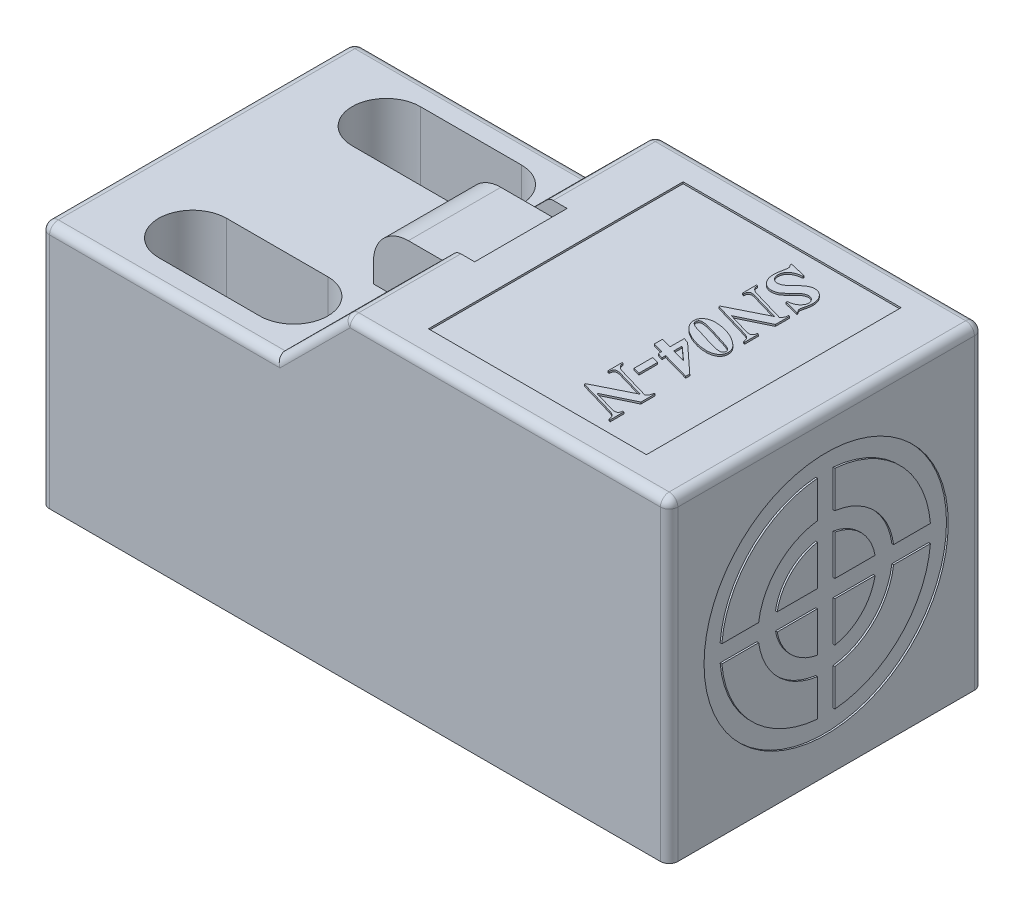
from build123d import *

# Parameters (mm, degrees)
EXTRUDE1_DEPTH  = 18
EXTRUDE2_DEPTH  = 17.9
LPATTERN1_COUNT = 2
LPATTERN1_PITCH = 11.1
SKETCH3_W       = 5.8
SKETCH3_H       = 5.3
EXTRUDE3_DEPTH  = 5
SKETCH4_W       = 5.8
SKETCH4_H       = 5.3
EXTRUDE4_DEPTH  = 1.85
FILLET1_R       = 2
EXTRUDE5_DEPTH  = 1.2
SKETCH6_R       = 1.6
EXTRUDE6_DEPTH  = 1
SKETCH7_W       = 12.5
SKETCH7_H       = 14.6
EXTRUDE7_DEPTH  = 0.1
SKETCH8_R       = 7
EXTRUDE8_DEPTH  = 0.1
FILLET3_R       = 0.5
EXTRUDE10_DEPTH = 0.1


with BuildPart() as part:
    # Sketch1 → Extrude1 (new body)
    with BuildSketch(Plane.XY):
        Polygon((-66.946751975, 32.479243645), (-48.446751975, 32.479243645), (-48.446751975, 14.379243645), (-84.466751975, 14.379243645), (-84.466751975, 28.479243645), (-70.966751975, 28.479243645), align=None)
    extrude(amount=EXTRUDE1_DEPTH)

    # Sketch2 → Extrude2 (cut)
    with BuildSketch(Plane(origin=(0, 28.479243645, 0), x_dir=(1, 0, 0), z_dir=(0, 1, 0))):
        with BuildLine():
            Line((-79.216751975, -12.6), (-73.416751975, -12.6))
            ThreePointArc((-73.416751975, -12.6), (-71.466751975, -14.55), (-73.416751975, -16.5))
            Line((-73.416751975, -16.5), (-79.216751975, -16.5))
            ThreePointArc((-79.216751975, -16.5), (-81.166751975, -14.55), (-79.216751975, -12.6))
        make_face()
    extrude2 = extrude(amount=-EXTRUDE2_DEPTH, mode=Mode.SUBTRACT)

    # LPattern1: Extrude2 ×2
    with Locations(*[(0, 0, -i * LPATTERN1_PITCH) for i in range(1, LPATTERN1_COUNT)]):
        add(extrude2, mode=Mode.SUBTRACT)

    # Sketch3 → Extrude3 (add)
    with BuildSketch(Plane(origin=(0, 28.479243645, 0), x_dir=(1, 0, 0), z_dir=(0, 1, 0))):
        with Locations((-68.846751975, -9)):
            Rectangle(SKETCH3_W, SKETCH3_H)
    extrude(amount=EXTRUDE3_DEPTH)

    # Sketch4 → Extrude4 (cut)
    with BuildSketch(Plane(origin=(0, 33.479243645, 0), x_dir=(1, 0, 0), z_dir=(0, 1, 0))):
        with Locations((-68.846751975, -9)):
            Rectangle(SKETCH4_W, SKETCH4_H)
    extrude(amount=-EXTRUDE4_DEPTH, mode=Mode.SUBTRACT)

    # Fillet1
    fillet1_edges = [part.edges().sort_by_distance(p)[0] for p in [
        (-71.746751975, 31.629243645, 9),
    ]]
    fillet(fillet1_edges, radius=FILLET1_R)

    # Sketch5 → Extrude5 (add)
    with BuildSketch(Plane.ZY.offset(84.466751975)):
        with BuildLine():
            Line((5, 14.379243645), (13, 14.379243645))
            Line((13, 14.379243645), (13, 20.389243645))
            ThreePointArc((13, 20.389243645), (11.831356057, 23.210599701), (9.01, 24.379243645))
            Line((9.01, 24.379243645), (8.99, 24.379243645))
            ThreePointArc((8.99, 24.379243645), (6.168643943, 23.210599701), (5, 20.389243645))
            Line((5, 20.389243645), (5, 14.379243645))
        make_face()
    extrude(amount=EXTRUDE5_DEPTH)

    # Sketch6 → Extrude6 (add)
    with BuildSketch(Plane.ZY.offset(85.666751975)):
        with Locations((8.99, 20.389243645)):
            Circle(SKETCH6_R)
    extrude(amount=EXTRUDE6_DEPTH)

    # Sketch7 → Extrude7 (cut)
    with BuildSketch(Plane(origin=(0, 32.479243645, 0), x_dir=(1, 0, 0), z_dir=(0, 1, 0))):
        with Locations((-57.696751975, -9)):
            Rectangle(SKETCH7_W, SKETCH7_H)
    extrude(amount=-EXTRUDE7_DEPTH, mode=Mode.SUBTRACT)

    # Sketch8 → Extrude8 (cut)
    with BuildSketch(Plane(origin=(-48.446751975, 0, 0), x_dir=(0, 0, -1), z_dir=(1, 0, 0))):
        with Locations((-9, 23.429243645)):
            Circle(SKETCH8_R)
        with BuildLine():
            Line((-9.5, 26.235041214), (-9.5, 23.929243645))
            Line((-9.5, 23.929243645), (-11.805797569, 23.929243645))
            ThreePointArc((-11.805797569, 23.929243645), (-11.015254326, 25.444497971), (-9.5, 26.235041214))
        make_face(mode=Mode.SUBTRACT)
        with BuildLine():
            Line((-14.979130372, 23.929243645), (-12.867815921, 23.929243645))
            ThreePointArc((-12.867815921, 23.929243645), (-11.757716447, 26.186960091), (-9.5, 27.297059566))
            Line((-9.5, 27.297059566), (-9.5, 29.408374016))
            ThreePointArc((-9.5, 29.408374016), (-13.242640687, 27.671884332), (-14.979130372, 23.929243645))
        make_face(mode=Mode.SUBTRACT)
        with BuildLine():
            Line((-8.5, 26.235041214), (-8.5, 23.929243645))
            Line((-8.5, 23.929243645), (-6.194202431, 23.929243645))
            ThreePointArc((-6.194202431, 23.929243645), (-6.984745674, 25.444497971), (-8.5, 26.235041214))
        make_face(mode=Mode.SUBTRACT)
        with BuildLine():
            Line((-8.5, 29.408374016), (-8.5, 27.297059566))
            ThreePointArc((-8.5, 27.297059566), (-6.242283553, 26.186960091), (-5.132184079, 23.929243645))
            Line((-5.132184079, 23.929243645), (-3.020869628, 23.929243645))
            ThreePointArc((-3.020869628, 23.929243645), (-4.757359313, 27.671884332), (-8.5, 29.408374016))
        make_face(mode=Mode.SUBTRACT)
        with BuildLine():
            Line((-5.132184079, 22.929243645), (-3.020869628, 22.929243645))
            ThreePointArc((-3.020869628, 22.929243645), (-4.757359313, 19.186602957), (-8.5, 17.450113273))
            Line((-8.5, 17.450113273), (-8.5, 19.561427723))
            ThreePointArc((-8.5, 19.561427723), (-6.242283553, 20.671527198), (-5.132184079, 22.929243645))
        make_face(mode=Mode.SUBTRACT)
        with BuildLine():
            Line((-14.979130372, 22.929243645), (-12.867815921, 22.929243645))
            ThreePointArc((-12.867815921, 22.929243645), (-11.757716447, 20.671527198), (-9.5, 19.561427723))
            Line((-9.5, 19.561427723), (-9.5, 17.450113273))
            ThreePointArc((-9.5, 17.450113273), (-13.242640687, 19.186602957), (-14.979130372, 22.929243645))
        make_face(mode=Mode.SUBTRACT)
        with BuildLine():
            Line((-9.5, 22.929243645), (-9.5, 20.623446075))
            ThreePointArc((-9.5, 20.623446075), (-11.015254326, 21.413989318), (-11.805797569, 22.929243645))
            Line((-11.805797569, 22.929243645), (-9.5, 22.929243645))
        make_face(mode=Mode.SUBTRACT)
        with BuildLine():
            Line((-8.5, 22.929243645), (-8.5, 20.623446075))
            ThreePointArc((-8.5, 20.623446075), (-6.984745674, 21.413989318), (-6.194202431, 22.929243645))
            Line((-6.194202431, 22.929243645), (-8.5, 22.929243645))
        make_face(mode=Mode.SUBTRACT)
    extrude(amount=-EXTRUDE8_DEPTH, mode=Mode.SUBTRACT)

    # Fillet3
    fillet3_edges = [part.edges().sort_by_distance(p)[0] for p in [
        (-66.946751975, 32.479243645, 3.175),
        (-66.946751975, 32.479243645, 14.825),
        (-57.696751975, 32.479243645, 18),
        (-68.956751975, 30.479243645, 18),
        (-77.716751975, 28.479243645, 18),
        (-84.466751975, 21.429243645, 18),
        (-48.446751975, 23.429243645, 18),
        (-84.466751975, 28.479243645, 9),
        (-84.466751975, 21.429243645, 0),
        (-77.716751975, 28.479243645, 0),
        (-68.956751975, 30.479243645, 0),
        (-48.446751975, 23.429243645, 0),
        (-48.446751975, 32.479243645, 9),
        (-57.696751975, 32.479243645, 0),
    ]]
    fillet(fillet3_edges, radius=FILLET3_R)

    # Sketch12 → Extrude10 (add)
    with BuildSketch(Plane(origin=(0, 32.379243645, 0), x_dir=(-1, 0, 0), z_dir=(0, 1, 0))):
        with BuildLine():
            Line((54.217585308, 13.848090278), (55.926569683, 14.672743056))
            Line((55.926569683, 14.672743056), (54.697728537, 15.036241319))
            add(Edge.make_bspline(
                [(54.697728537, 15.036241319), (54.680770727, 15.040417409), (54.647928955, 15.048505139), (54.599724774, 15.056993208), (54.554470721, 15.063025175), (54.525220345, 15.063622276), (54.511096593, 15.06391059)],
                knots=[0, 0, 0, 0, 5.2376e-05, 0.000101436, 0.000146792, 0.000189141, 0.000189141, 0.000189141, 0.000189141], degree=3))
            add(Edge.make_bspline(
                [(54.511096593, 15.06391059), (54.495660528, 15.063188838), (54.465825954, 15.061793846), (54.423520353, 15.050905397), (54.386009201, 15.032506175), (54.353030605, 15.006683404), (54.326421974, 14.970974423), (54.306166824, 14.925521479), (54.293462491, 14.869711329), (54.289272375, 14.829052805), (54.287029753, 14.807291667)],
                knots=[0, 0, 0, 0, 4.6272e-05, 8.9433e-05, 0.000129953, 0.000170877, 0.000213847, 0.00026216, 0.000319137, 0.000384747, 0.000384747, 0.000384747, 0.000384747], degree=3))
            Line((54.287029753, 14.807291667), (54.217585308, 14.827365451))
            Line((54.217585308, 14.827365451), (54.217585308, 15.614040799))
            Line((54.217585308, 15.614040799), (54.287029753, 15.595594618))
            add(Edge.make_bspline(
                [(54.287029753, 15.595594618), (54.289286674, 15.571630477), (54.293663741, 15.525154502), (54.310486441, 15.459042694), (54.335936725, 15.399579854), (54.363275272, 15.354199491), (54.392013639, 15.32227373), (54.417481963, 15.298496648), (54.448932431, 15.277304402), (54.484255978, 15.256157011), (54.523972054, 15.235110284), (54.569197382, 15.216826207), (54.618575853, 15.197962016), (54.653530655, 15.187220158), (54.671686871, 15.181640625)],
                knots=[0, 0, 0, 0, 7.2139e-05, 0.000139906, 0.000203593, 0.00026576, 0.000297659, 0.00033222, 0.000369999, 0.000411124, 0.000455774, 0.000504644, 0.000557348, 0.000614312, 0.000614312, 0.000614312, 0.000614312], degree=3))
            Line((54.671686871, 15.181640625), (56.717585308, 14.582139757))
            Line((56.717585308, 14.582139757), (56.717585308, 14.520833333))
            Line((56.717585308, 14.520833333), (54.628284093, 13.475911458))
            Line((54.628284093, 13.475911458), (56.278132183, 12.99468316))
            add(Edge.make_bspline(
                [(56.278132183, 12.99468316), (56.305120853, 12.987961491), (56.355417393, 12.975434875), (56.407152473, 12.97264638), (56.431126975, 12.971354167)],
                knots=[0, 0, 0, 0, 8.3211e-05, 0.000155074, 0.000155074, 0.000155074, 0.000155074], degree=3))
            add(Edge.make_bspline(
                [(56.431126975, 12.971354167), (56.446775033, 12.971935765), (56.477170895, 12.9730655), (56.520027609, 12.986041052), (56.558083011, 13.006488341), (56.591007111, 13.035434664), (56.617629686, 13.073943195), (56.63561898, 13.122344572), (56.646271582, 13.179947477), (56.647487184, 13.221410316), (56.648140864, 13.243706597)],
                knots=[0, 0, 0, 0, 4.6812e-05, 9.0931e-05, 0.000132931, 0.000175599, 0.000221201, 0.000271878, 0.000329335, 0.000396175, 0.000396175, 0.000396175, 0.000396175], degree=3))
            Line((56.648140864, 13.243706597), (56.717585308, 13.227430556))
            Line((56.717585308, 13.227430556), (56.717585308, 12.417426215))
            Line((56.717585308, 12.417426215), (56.648140864, 12.433702257))
            add(Edge.make_bspline(
                [(56.648140864, 12.433702257), (56.647971318, 12.449987788), (56.647660068, 12.479884593), (56.644547386, 12.521040216), (56.63933653, 12.554709903), (56.632637568, 12.573918393), (56.629694683, 12.582356771)],
                knots=[0, 0, 0, 0, 4.884e-05, 8.966e-05, 0.000123823, 0.000150589, 0.000150589, 0.000150589, 0.000150589], degree=3))
            add(Edge.make_bspline(
                [(56.629694683, 12.582356771), (56.624140867, 12.595416153), (56.612704566, 12.622307756), (56.586595207, 12.659979875), (56.554461873, 12.697252537), (56.515886075, 12.734622762), (56.468783261, 12.769419962), (56.412526981, 12.801089882), (56.34696509, 12.82904401), (56.29926507, 12.843761717), (56.27433444, 12.851453993)],
                knots=[0, 0, 0, 0, 4.2477e-05, 8.7469e-05, 0.000136723, 0.00019006, 0.00024822, 0.000311879, 0.000383331, 0.000461566, 0.000461566, 0.000461566, 0.000461566], degree=3))
            Line((56.27433444, 12.851453993), (54.45901326, 13.382052951))
            add(Edge.make_bspline(
                [(54.45901326, 13.382052951), (54.442312569, 13.367118213), (54.411205191, 13.339300168), (54.37160966, 13.297050314), (54.341169804, 13.258973076), (54.318437097, 13.222982605), (54.304452683, 13.183716381), (54.295198532, 13.13881583), (54.288629426, 13.086010291), (54.28758678, 13.048055097), (54.287029753, 13.027777778)],
                knots=[0, 0, 0, 0, 6.7189e-05, 0.000125149, 0.000173447, 0.000213363, 0.00025216, 0.000297707, 0.000350735, 0.000411559, 0.000411559, 0.000411559, 0.000411559], degree=3))
            Line((54.287029753, 13.027777778), (54.217585308, 13.027777778))
            Line((54.217585308, 13.027777778), (54.217585308, 13.848090278))
        make_face()
        Polygon((55.710640864, 11.395833333), (55.710640864, 12.472222222), (56.092585308, 12.368055556), (56.092585308, 11.291666667), align=None)
        Polygon((56.12730753, 10.274956597), (56.12730753, 9.451388889), (55.834881315, 9.555555556), (54.217585308, 11.048611111), (54.217585308, 11.281901042), (55.81480753, 10.831054687), (55.81480753, 11.048611111), (56.12730753, 10.944444444), (56.12730753, 10.743164062), (56.717585308, 10.576605903), (56.717585308, 10.108398437), align=None)
        Polygon((55.81480753, 10.362847222), (55.036812739, 10.582573785), (55.81480753, 9.886501736), align=None, mode=Mode.SUBTRACT)
        with BuildLine():
            add(Edge.make_bspline(
                [(54.182863086, 8.87358941), (54.184073107, 8.902277151), (54.186429627, 8.95814661), (54.206051358, 9.038769036), (54.238065837, 9.113086374), (54.28410285, 9.179601659), (54.339840378, 9.238578555), (54.404850306, 9.289131258), (54.478375762, 9.33064365), (54.559399701, 9.362355092), (54.643984551, 9.385996948), (54.729207587, 9.403420534), (54.813692255, 9.415005581), (54.870037246, 9.41611673), (54.89792385, 9.416666667)],
                knots=[0, 0, 0, 0, 8.5967e-05, 0.000167422, 0.000247353, 0.000327408, 0.00040877, 0.000489947, 0.000573526, 0.000661175, 0.000750304, 0.000836702, 0.00092203, 0.001005644, 0.001005644, 0.001005644, 0.001005644], degree=3))
            add(Edge.make_bspline(
                [(54.89792385, 9.416666667), (54.946602995, 9.415663052), (55.04488093, 9.413636864), (55.193295036, 9.398996546), (55.343857591, 9.375143042), (55.495133524, 9.341338623), (55.64475773, 9.300364767), (55.789328928, 9.250609989), (55.928307477, 9.194577375), (56.05964948, 9.129825518), (56.183530154, 9.061208726), (56.297225446, 8.987658834), (56.401138961, 8.911074603), (56.463552935, 8.854921635), (56.494061003, 8.827473958)],
                knots=[0, 0, 0, 0, 0.000146024, 0.000294806, 0.000446972, 0.000603091, 0.000759594, 0.00091212, 0.00106153, 0.001208813, 0.001351144, 0.001486132, 0.001614821, 0.001737872, 0.001737872, 0.001737872, 0.001737872], degree=3))
            add(Edge.make_bspline(
                [(56.494061003, 8.827473958), (56.511999376, 8.809380068), (56.548089878, 8.772976679), (56.595539799, 8.711258763), (56.639963861, 8.645136554), (56.678329319, 8.573606989), (56.711062611, 8.499302649), (56.735488665, 8.423098316), (56.749137295, 8.345470029), (56.751252996, 8.293487786), (56.75230753, 8.267578125)],
                knots=[0, 0, 0, 0, 7.6366e-05, 0.000153643, 0.000233092, 0.000315144, 0.000396784, 0.000476402, 0.000554627, 0.000632363, 0.000632363, 0.000632363, 0.000632363], degree=3))
            add(Edge.make_bspline(
                [(56.75230753, 8.267578125), (56.751262696, 8.243982671), (56.749187726, 8.197123741), (56.732562279, 8.128517228), (56.70395784, 8.063796757), (56.666293972, 8.002057848), (56.616694827, 7.946110483), (56.557508962, 7.895635422), (56.487839387, 7.85230173), (56.40945265, 7.816096574), (56.325179526, 7.786477098), (56.236660825, 7.765265233), (56.14521883, 7.752580866), (56.08322121, 7.750866321), (56.051895204, 7.75)],
                knots=[0, 0, 0, 0, 7.0738e-05, 0.00014048, 0.000210223, 0.000282339, 0.000356548, 0.000433519, 0.000514952, 0.00060184, 0.000692094, 0.000782495, 0.000874491, 0.00096845, 0.00096845, 0.00096845, 0.00096845], degree=3))
            add(Edge.make_bspline(
                [(56.051895204, 7.75), (56.01697697, 7.750324468), (55.94705627, 7.750974185), (55.842272889, 7.759160261), (55.737323416, 7.771117017), (55.632182659, 7.786957846), (55.52719588, 7.809254594), (55.422096078, 7.834961154), (55.316927598, 7.865988639), (55.247581201, 7.890224554), (55.212593989, 7.902452257)],
                knots=[0, 0, 0, 0, 0.000104732, 0.000209716, 0.000315103, 0.000421606, 0.00052854, 0.000636966, 0.000746146, 0.000857322, 0.000857322, 0.000857322, 0.000857322], degree=3))
            add(Edge.make_bspline(
                [(55.212593989, 7.902452257), (55.156024735, 7.924098005), (55.045344794, 7.966448752), (54.888262531, 8.041804861), (54.742815702, 8.124126402), (54.631180661, 8.199659151), (54.549555227, 8.262433129), (54.494094262, 8.308135266), (54.443538948, 8.352384521), (54.398406653, 8.395961654), (54.358155105, 8.438102306), (54.32302898, 8.479352121), (54.293903119, 8.520095509), (54.261465337, 8.571628412), (54.229962243, 8.636286645), (54.203318172, 8.715107287), (54.186035986, 8.79417427), (54.183914147, 8.847282195), (54.182863086, 8.87358941)],
                knots=[0, 0, 0, 0, 0.000181645, 0.000355396, 0.000522082, 0.00068264, 0.000759251, 0.000830939, 0.000898207, 0.000960749, 0.001019081, 0.001072986, 0.001123126, 0.00116919, 0.001255569, 0.001338094, 0.001418427, 0.001497282, 0.001497282, 0.001497282, 0.001497282], degree=3))
        make_face()
        with BuildLine():
            add(Edge.make_bspline(
                [(54.287029753, 8.895833333), (54.288042002, 8.877841001), (54.289967896, 8.843609005), (54.303127144, 8.802199263), (54.322120838, 8.773549375), (54.340805233, 8.75094087), (54.36542117, 8.728156338), (54.389454289, 8.708090337), (54.413300391, 8.691928999), (54.436475986, 8.678991558), (54.463938061, 8.66495514), (54.496271088, 8.650382963), (54.532932808, 8.634684887), (54.57420812, 8.618473607), (54.620037451, 8.601658577), (54.652142072, 8.590348278), (54.668974197, 8.584418403)],
                knots=[0, 0, 0, 0, 5.3984e-05, 0.00010271, 0.000127843, 0.00015674, 0.000190508, 0.000228299, 0.000250569, 0.000276814, 0.000307871, 0.000343073, 0.000383181, 0.000427509, 0.000476087, 0.000529625, 0.000529625, 0.000529625, 0.000529625], degree=3))
            add(Edge.make_bspline(
                [(54.668974197, 8.584418403), (54.701869723, 8.572971863), (54.769387367, 8.549477987), (54.873447318, 8.51442673), (54.982532774, 8.477811304), (55.097133902, 8.441114344), (55.21703316, 8.403133402), (55.342264402, 8.363936981), (55.472967565, 8.32458109), (55.561802775, 8.297950648), (55.607016732, 8.284396701)],
                knots=[0, 0, 0, 0, 0.00010449, 0.000214464, 0.000329412, 0.000449685, 0.000575456, 0.000706728, 0.000843345, 0.000984951, 0.000984951, 0.000984951, 0.000984951], degree=3))
            add(Edge.make_bspline(
                [(55.607016732, 8.284396701), (55.641000335, 8.274397342), (55.705678277, 8.25536646), (55.798045526, 8.229076342), (55.880432113, 8.204645895), (55.953727651, 8.185047214), (56.01706595, 8.167347966), (56.071062768, 8.15346937), (56.115174105, 8.141600201), (56.14175304, 8.136010699), (56.153349197, 8.133572049)],
                knots=[0, 0, 0, 0, 0.000106272, 0.000202257, 0.000288108, 0.000364052, 0.000429859, 0.000485392, 0.000531315, 0.000566859, 0.000566859, 0.000566859, 0.000566859], degree=3))
            add(Edge.make_bspline(
                [(56.153349197, 8.133572049), (56.181157321, 8.128083401), (56.234613431, 8.117532466), (56.312633483, 8.106182338), (56.385218072, 8.098489059), (56.432013688, 8.097632846), (56.454455968, 8.097222222)],
                knots=[0, 0, 0, 0, 8.5019e-05, 0.000163433, 0.000236474, 0.000303784, 0.000303784, 0.000303784, 0.000303784], degree=3))
            add(Edge.make_bspline(
                [(56.454455968, 8.097222222), (56.468799826, 8.097810642), (56.496009448, 8.098926845), (56.534553818, 8.108315683), (56.568403318, 8.12407601), (56.596769411, 8.146724824), (56.619529038, 8.173758032), (56.636175391, 8.2041694), (56.646448929, 8.237630983), (56.647566396, 8.260993341), (56.648140864, 8.273003472)],
                knots=[0, 0, 0, 0, 4.2984e-05, 8.1538e-05, 0.000118182, 0.000154108, 0.000189536, 0.000223525, 0.000257511, 0.000293466, 0.000293466, 0.000293466, 0.000293466], degree=3))
            add(Edge.make_bspline(
                [(56.648140864, 8.273003472), (56.647643881, 8.285533338), (56.646690289, 8.309575205), (56.638752435, 8.343752456), (56.626752723, 8.374954205), (56.61383207, 8.392417042), (56.60745076, 8.401041667)],
                knots=[0, 0, 0, 0, 3.7533e-05, 7.2017e-05, 0.000104862, 0.000136913, 0.000136913, 0.000136913, 0.000136913], degree=3))
            add(Edge.make_bspline(
                [(56.60745076, 8.401041667), (56.59175107, 8.417977243), (56.558599868, 8.453738123), (56.493394786, 8.496726648), (56.416080054, 8.537522352), (56.357858201, 8.558235252), (56.326960308, 8.569227431)],
                knots=[0, 0, 0, 0, 6.9053e-05, 0.000145812, 0.000232685, 0.000330922, 0.000330922, 0.000330922, 0.000330922], degree=3))
            add(Edge.make_bspline(
                [(56.326960308, 8.569227431), (56.286442754, 8.582583874), (56.201985777, 8.610424764), (56.070167023, 8.654465237), (55.926700936, 8.698738049), (55.772897813, 8.747549639), (55.607686949, 8.797460951), (55.432248398, 8.851763847), (55.245281936, 8.906534566), (55.117274553, 8.944614429), (55.051461176, 8.964192708)],
                knots=[0, 0, 0, 0, 0.000127988, 0.000266784, 0.000416925, 0.000578394, 0.00075087, 0.000934674, 0.001129337, 0.001335329, 0.001335329, 0.001335329, 0.001335329], degree=3))
            add(Edge.make_bspline(
                [(55.051461176, 8.964192708), (55.022358885, 8.972375609), (54.966062715, 8.988204808), (54.883993542, 9.010485274), (54.80637077, 9.027917765), (54.733652176, 9.043696954), (54.66552357, 9.054855787), (54.602214027, 9.063196124), (54.54373568, 9.068373989), (54.506222926, 9.069098488), (54.488310135, 9.069444444)],
                knots=[0, 0, 0, 0, 9.0696e-05, 0.000175444, 0.000255066, 0.000329335, 0.000398638, 0.000462096, 0.000520893, 0.000574628, 0.000574628, 0.000574628, 0.000574628], degree=3))
            add(Edge.make_bspline(
                [(54.488310135, 9.069444444), (54.473436268, 9.068819417), (54.445002973, 9.067624599), (54.404491462, 9.058580937), (54.369227667, 9.042112915), (54.339773568, 9.019620384), (54.316126257, 8.993118948), (54.299721436, 8.96293923), (54.288600318, 8.930418908), (54.287559585, 8.907500819), (54.287029753, 8.895833333)],
                knots=[0, 0, 0, 0, 4.4607e-05, 8.5272e-05, 0.000123619, 0.000160404, 0.000195773, 0.000229287, 0.000262915, 0.00029779, 0.00029779, 0.00029779, 0.00029779], degree=3))
        make_face(mode=Mode.SUBTRACT)
        with BuildLine():
            Line((54.217585308, 6.139756944), (55.926569683, 6.964409722))
            Line((55.926569683, 6.964409722), (54.697728537, 7.327907986))
            add(Edge.make_bspline(
                [(54.697728537, 7.327907986), (54.680770727, 7.332084076), (54.647928955, 7.340171806), (54.599724774, 7.348659874), (54.554470721, 7.354691842), (54.525220345, 7.355288943), (54.511096593, 7.355577257)],
                knots=[0, 0, 0, 0, 5.2376e-05, 0.000101436, 0.000146792, 0.000189141, 0.000189141, 0.000189141, 0.000189141], degree=3))
            add(Edge.make_bspline(
                [(54.511096593, 7.355577257), (54.495660528, 7.354855504), (54.465825954, 7.353460512), (54.423520353, 7.342572063), (54.386009201, 7.324172842), (54.353030605, 7.29835007), (54.326421974, 7.262641089), (54.306166824, 7.217188145), (54.293462491, 7.161377995), (54.289272375, 7.120719471), (54.287029753, 7.098958333)],
                knots=[0, 0, 0, 0, 4.6272e-05, 8.9433e-05, 0.000129953, 0.000170877, 0.000213847, 0.00026216, 0.000319137, 0.000384747, 0.000384747, 0.000384747, 0.000384747], degree=3))
            Line((54.287029753, 7.098958333), (54.217585308, 7.119032118))
            Line((54.217585308, 7.119032118), (54.217585308, 7.905707465))
            Line((54.217585308, 7.905707465), (54.287029753, 7.887261285))
            add(Edge.make_bspline(
                [(54.287029753, 7.887261285), (54.289286674, 7.863297144), (54.293663741, 7.816821169), (54.310486441, 7.750709361), (54.335936725, 7.691246521), (54.363275272, 7.645866158), (54.392013639, 7.613940397), (54.417481963, 7.590163315), (54.448932431, 7.568971069), (54.484255978, 7.547823678), (54.523972054, 7.52677695), (54.569197382, 7.508492874), (54.618575853, 7.489628682), (54.653530655, 7.478886825), (54.671686871, 7.473307292)],
                knots=[0, 0, 0, 0, 7.2139e-05, 0.000139906, 0.000203593, 0.00026576, 0.000297659, 0.00033222, 0.000369999, 0.000411124, 0.000455774, 0.000504644, 0.000557348, 0.000614312, 0.000614312, 0.000614312, 0.000614312], degree=3))
            Line((54.671686871, 7.473307292), (56.717585308, 6.873806424))
            Line((56.717585308, 6.873806424), (56.717585308, 6.8125))
            Line((56.717585308, 6.8125), (54.628284093, 5.767578125))
            Line((54.628284093, 5.767578125), (56.278132183, 5.286349826))
            add(Edge.make_bspline(
                [(56.278132183, 5.286349826), (56.305120853, 5.279628157), (56.355417393, 5.267101542), (56.407152473, 5.264313047), (56.431126975, 5.263020833)],
                knots=[0, 0, 0, 0, 8.3211e-05, 0.000155074, 0.000155074, 0.000155074, 0.000155074], degree=3))
            add(Edge.make_bspline(
                [(56.431126975, 5.263020833), (56.446775033, 5.263602431), (56.477170895, 5.264732167), (56.520027609, 5.277707719), (56.558083011, 5.298155008), (56.591007111, 5.32710133), (56.617629686, 5.365609862), (56.63561898, 5.414011239), (56.646271582, 5.471614143), (56.647487184, 5.513076983), (56.648140864, 5.535373264)],
                knots=[0, 0, 0, 0, 4.6812e-05, 9.0931e-05, 0.000132931, 0.000175599, 0.000221201, 0.000271878, 0.000329335, 0.000396175, 0.000396175, 0.000396175, 0.000396175], degree=3))
            Line((56.648140864, 5.535373264), (56.717585308, 5.519097222))
            Line((56.717585308, 5.519097222), (56.717585308, 4.709092882))
            Line((56.717585308, 4.709092882), (56.648140864, 4.725368924))
            add(Edge.make_bspline(
                [(56.648140864, 4.725368924), (56.647971318, 4.741654455), (56.647660068, 4.77155126), (56.644547386, 4.812706882), (56.63933653, 4.84637657), (56.632637568, 4.86558506), (56.629694683, 4.874023438)],
                knots=[0, 0, 0, 0, 4.884e-05, 8.966e-05, 0.000123823, 0.000150589, 0.000150589, 0.000150589, 0.000150589], degree=3))
            add(Edge.make_bspline(
                [(56.629694683, 4.874023438), (56.624140867, 4.88708282), (56.612704566, 4.913974422), (56.586595207, 4.951646542), (56.554461873, 4.988919204), (56.515886075, 5.026289429), (56.468783261, 5.061086629), (56.412526981, 5.092756548), (56.34696509, 5.120710677), (56.29926507, 5.135428384), (56.27433444, 5.14312066)],
                knots=[0, 0, 0, 0, 4.2477e-05, 8.7469e-05, 0.000136723, 0.00019006, 0.00024822, 0.000311879, 0.000383331, 0.000461566, 0.000461566, 0.000461566, 0.000461566], degree=3))
            Line((56.27433444, 5.14312066), (54.45901326, 5.673719618))
            add(Edge.make_bspline(
                [(54.45901326, 5.673719618), (54.442312569, 5.65878488), (54.411205191, 5.630966835), (54.37160966, 5.588716981), (54.341169804, 5.550639743), (54.318437097, 5.514649272), (54.304452683, 5.475383047), (54.295198532, 5.430482496), (54.288629426, 5.377676958), (54.28758678, 5.339721764), (54.287029753, 5.319444444)],
                knots=[0, 0, 0, 0, 6.7189e-05, 0.000125149, 0.000173447, 0.000213363, 0.00025216, 0.000297707, 0.000350735, 0.000411559, 0.000411559, 0.000411559, 0.000411559], degree=3))
            Line((54.287029753, 5.319444444), (54.217585308, 5.319444444))
            Line((54.217585308, 5.319444444), (54.217585308, 6.139756944))
        make_face()
        with BuildLine():
            Line((54.182863086, 4.939670139), (55.016196419, 4.724826389))
            Line((55.016196419, 4.724826389), (55.016196419, 4.661892361))
            add(Edge.make_bspline(
                [(55.016196419, 4.661892361), (54.983952693, 4.658295211), (54.922652927, 4.651456533), (54.835971958, 4.635790102), (54.759287907, 4.616300898), (54.712618057, 4.598969097), (54.690675586, 4.590820313)],
                knots=[0, 0, 0, 0, 9.7306e-05, 0.000184992, 0.000264079, 0.00033426, 0.00033426, 0.00033426, 0.00033426], degree=3))
            add(Edge.make_bspline(
                [(54.690675586, 4.590820313), (54.662463088, 4.577761813), (54.607776743, 4.552449571), (54.533894112, 4.504206166), (54.470347887, 4.449537116), (54.416862481, 4.389511697), (54.374913272, 4.324575371), (54.343819264, 4.256793235), (54.325158393, 4.185632811), (54.32289111, 4.137187333), (54.321751975, 4.112847222)],
                knots=[0, 0, 0, 0, 9.3171e-05, 0.0001806, 0.000263691, 0.000344024, 0.000420923, 0.000494739, 0.00056698, 0.000639924, 0.000639924, 0.000639924, 0.000639924], degree=3))
            add(Edge.make_bspline(
                [(54.321751975, 4.112847222), (54.323106658, 4.089722162), (54.32578691, 4.043969028), (54.347461952, 3.977798959), (54.383136342, 3.91663946), (54.431004215, 3.861934511), (54.486868292, 3.815523071), (54.548780312, 3.781822819), (54.61442174, 3.760476501), (54.65977457, 3.75812479), (54.682537565, 3.756944444)],
                knots=[0, 0, 0, 0, 6.9262e-05, 0.000137035, 0.00020655, 0.000280402, 0.000354037, 0.000423229, 0.000490839, 0.000558968, 0.000558968, 0.000558968, 0.000558968], degree=3))
            add(Edge.make_bspline(
                [(54.682537565, 3.756944444), (54.705379119, 3.758003685), (54.751448317, 3.760140069), (54.820230529, 3.773886146), (54.887835231, 3.797990062), (54.94428922, 3.824504258), (54.990837534, 3.853315695), (55.030176832, 3.881834101), (55.074226573, 3.915907576), (55.121914943, 3.956953591), (55.173816969, 4.004197324), (55.230352862, 4.057448626), (55.291088087, 4.117004633), (55.332234943, 4.159584919), (55.353653017, 4.181749132)],
                knots=[0, 0, 0, 0, 6.8534e-05, 0.000138225, 0.00020943, 0.000283442, 0.000324849, 0.000373475, 0.000429147, 0.000491878, 0.000562167, 0.000639694, 0.000724863, 0.000817325, 0.000817325, 0.000817325, 0.000817325], degree=3))
            add(Edge.make_bspline(
                [(55.353653017, 4.181749132), (55.37056517, 4.199555599), (55.403417336, 4.234144984), (55.452601061, 4.283041264), (55.500513517, 4.326832316), (55.545882997, 4.366761217), (55.589992774, 4.40157067), (55.632253682, 4.431853227), (55.672296765, 4.458328999), (55.72360017, 4.486302463), (55.788331486, 4.514320937), (55.868809977, 4.538190938), (55.952631263, 4.552710496), (56.009520072, 4.554599072), (56.038331836, 4.555555556)],
                knots=[0, 0, 0, 0, 7.3673e-05, 0.000143111, 0.000208, 0.000268378, 0.000324385, 0.00037648, 0.000424334, 0.000468282, 0.000551631, 0.0006354, 0.000719598, 0.000805999, 0.000805999, 0.000805999, 0.000805999], degree=3))
            add(Edge.make_bspline(
                [(56.038331836, 4.555555556), (56.070616622, 4.55431075), (56.134701757, 4.551839818), (56.228784443, 4.531805479), (56.318689872, 4.498163222), (56.403959548, 4.452045087), (56.482938381, 4.393452038), (56.553085271, 4.322128022), (56.613094612, 4.238454222), (56.663164488, 4.143967744), (56.703072978, 4.040481976), (56.731904382, 3.929676597), (56.748805852, 3.812079475), (56.751121175, 3.731500679), (56.75230753, 3.690212674)],
                knots=[0, 0, 0, 0, 9.679e-05, 0.000192128, 0.00028706, 0.00038392, 0.000482011, 0.00058099, 0.000682785, 0.000789823, 0.000900953, 0.001014779, 0.001132631, 0.001256472, 0.001256472, 0.001256472, 0.001256472], degree=3))
            add(Edge.make_bspline(
                [(56.75230753, 3.690212674), (56.751600516, 3.662519848), (56.750094962, 3.60354925), (56.739524226, 3.510299025), (56.723253565, 3.406935056), (56.704208669, 3.316326564), (56.688649796, 3.242442982), (56.677488372, 3.190850146), (56.669202211, 3.143867125), (56.661046965, 3.102241793), (56.65607519, 3.065217429), (56.651237425, 3.033483545), (56.649182115, 3.006461291), (56.648466492, 2.99016338), (56.648140864, 2.982747396)],
                knots=[0, 0, 0, 0, 8.3072e-05, 0.000176897, 0.000281256, 0.000396912, 0.000454585, 0.000507786, 0.000555245, 0.000597705, 0.000634994, 0.000667297, 0.000693969, 0.00071624, 0.00071624, 0.00071624, 0.00071624], degree=3))
            add(Edge.make_bspline(
                [(56.648140864, 2.982747396), (56.649156504, 2.963121309), (56.65111121, 2.925348823), (56.664666747, 2.879110423), (56.683347096, 2.844564562), (56.701429091, 2.815417322), (56.72483558, 2.783663262), (56.742786306, 2.762021511), (56.75230753, 2.750542535)],
                knots=[0, 0, 0, 0, 5.8844e-05, 0.000113252, 0.000142614, 0.000176487, 0.000216096, 0.000260834, 0.000260834, 0.000260834, 0.000260834], degree=3))
            Line((56.75230753, 2.750542535), (56.75230753, 2.68109809))
            Line((56.75230753, 2.68109809), (55.81480753, 2.892686632))
            Line((55.81480753, 2.892686632), (55.81480753, 2.958875868))
            add(Edge.make_bspline(
                [(55.81480753, 2.958875868), (55.855048277, 2.963310921), (55.932886304, 2.971889682), (56.04411551, 2.994535584), (56.146476343, 3.022381578), (56.23964289, 3.057330214), (56.323552549, 3.100174276), (56.397812056, 3.151637591), (56.462242689, 3.211500266), (56.516311511, 3.279451927), (56.560167298, 3.353729916), (56.591022749, 3.434233379), (56.610348982, 3.519667158), (56.612381454, 3.578345743), (56.613418642, 3.608289931)],
                knots=[0, 0, 0, 0, 0.000121397, 0.000234819, 0.000340123, 0.000439372, 0.000532792, 0.000622041, 0.000709562, 0.000795647, 0.000881719, 0.000967257, 0.00105335, 0.001143067, 0.001143067, 0.001143067, 0.001143067], degree=3))
            add(Edge.make_bspline(
                [(56.613418642, 3.608289931), (56.61321502, 3.623143709), (56.612813466, 3.652436232), (56.606387793, 3.695228235), (56.597335184, 3.736327169), (56.584387519, 3.775495856), (56.567184865, 3.812502088), (56.547402432, 3.84823101), (56.522468182, 3.881147311), (56.495123538, 3.912569704), (56.46500831, 3.940925229), (56.43348438, 3.966065409), (56.400685073, 3.987470841), (56.366571479, 4.004995814), (56.330724693, 4.017885793), (56.293975699, 4.02796381), (56.255673836, 4.033197746), (56.229859487, 4.034210753), (56.21682576, 4.034722222)],
                knots=[0, 0, 0, 0, 4.4518e-05, 8.7791e-05, 0.000129514, 0.000170689, 0.000211234, 0.000251812, 0.000292938, 0.000334839, 0.000376671, 0.000416833, 0.000455658, 0.000493994, 0.000531585, 0.000569748, 0.000608111, 0.000647234, 0.000647234, 0.000647234, 0.000647234], degree=3))
            add(Edge.make_bspline(
                [(56.21682576, 4.034722222), (56.194340923, 4.033887932), (56.149534213, 4.032225399), (56.083031194, 4.018712466), (56.018361389, 3.996106324), (55.965094353, 3.970503428), (55.921198695, 3.94395702), (55.884733915, 3.917559464), (55.843699009, 3.886676835), (55.799317178, 3.849575655), (55.751412463, 3.806823068), (55.699501144, 3.758708035), (55.643829201, 3.705130899), (55.58562457, 3.647226128), (55.527087979, 3.588361039), (55.468398601, 3.533609641), (55.411538255, 3.483499557), (55.356009339, 3.438695041), (55.303210479, 3.397537174), (55.251252023, 3.36238784), (55.201718446, 3.33116287), (55.168395677, 3.313504119), (55.152372635, 3.305013021)],
                knots=[0, 0, 0, 0, 6.7414e-05, 0.00013434, 0.000202626, 0.00027251, 0.000311216, 0.000356374, 0.000407482, 0.000465277, 0.00052984, 0.000600096, 0.000677605, 0.00076162, 0.000846403, 0.000926627, 0.001002367, 0.001073711, 0.001140663, 0.001203114, 0.00126183, 0.001316214, 0.001316214, 0.001316214, 0.001316214], degree=3))
            add(Edge.make_bspline(
                [(55.152372635, 3.305013021), (55.128924017, 3.294246112), (55.082505327, 3.272932029), (55.00842894, 3.252189532), (54.932613676, 3.238542869), (54.880984899, 3.236923932), (54.855063607, 3.236111111)],
                knots=[0, 0, 0, 0, 7.7294e-05, 0.00015301, 0.000230073, 0.000307776, 0.000307776, 0.000307776, 0.000307776], degree=3))
            add(Edge.make_bspline(
                [(54.855063607, 3.236111111), (54.83259564, 3.236667006), (54.788318083, 3.237762508), (54.723013354, 3.248594666), (54.659958924, 3.265724117), (54.599367447, 3.290587393), (54.541117979, 3.321534157), (54.485073301, 3.359507074), (54.431679012, 3.404626139), (54.380690427, 3.455922426), (54.334517149, 3.513104738), (54.293384798, 3.574621357), (54.259079362, 3.640684818), (54.231436005, 3.711142859), (54.209836674, 3.785630632), (54.193987491, 3.864172775), (54.184782619, 3.94697353), (54.183512619, 4.003593957), (54.182863086, 4.032552083)],
                knots=[0, 0, 0, 0, 6.7353e-05, 0.000132732, 0.000198017, 0.000262999, 0.000328773, 0.000395585, 0.000465675, 0.000538182, 0.000612237, 0.000685818, 0.00075983, 0.000835088, 0.000912518, 0.000992212, 0.001075191, 0.001162058, 0.001162058, 0.001162058, 0.001162058], degree=3))
            add(Edge.make_bspline(
                [(54.182863086, 4.032552083), (54.183901227, 4.061697447), (54.186132793, 4.124347707), (54.198824357, 4.224396206), (54.219685727, 4.33677795), (54.238541829, 4.415303197), (54.248509787, 4.456814236)],
                knots=[0, 0, 0, 0, 8.7456e-05, 0.000187993, 0.000302175, 0.000430228, 0.000430228, 0.000430228, 0.000430228], degree=3))
            add(Edge.make_bspline(
                [(54.248509787, 4.456814236), (54.254317422, 4.480644772), (54.264929873, 4.524190969), (54.276683824, 4.584306724), (54.285433338, 4.632707357), (54.286551374, 4.661505949), (54.287029753, 4.673828125)],
                knots=[0, 0, 0, 0, 7.3563e-05, 0.000134424, 0.000183839, 0.000220795, 0.000220795, 0.000220795, 0.000220795], degree=3))
            add(Edge.make_bspline(
                [(54.287029753, 4.673828125), (54.28604344, 4.690955704), (54.284139782, 4.724013224), (54.270160191, 4.76387333), (54.252395236, 4.793598243), (54.234386352, 4.8180758), (54.210831165, 4.84410647), (54.192587198, 4.861144404), (54.182863086, 4.870225694)],
                knots=[0, 0, 0, 0, 5.1286e-05, 9.8986e-05, 0.000124761, 0.000155036, 0.000189999, 0.000229904, 0.000229904, 0.000229904, 0.000229904], degree=3))
            Line((54.182863086, 4.870225694), (54.182863086, 4.939670139))
        make_face()
    extrude(amount=EXTRUDE10_DEPTH)


solid = part.part
